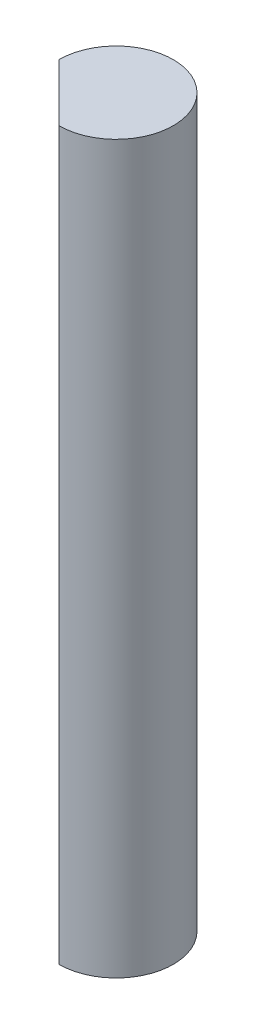
from build123d import *

# Parameters (mm, degrees)
BOSS_EXTRUDE1_DEPTH = 50.8


with BuildPart() as part:
    # Sketch1 → Boss-Extrude1 (new body)
    with BuildSketch(Plane(origin=(0, 0, 0), x_dir=(1, 0, 0), z_dir=(0, 1, 0))):
        with BuildLine():
            Line((-4, 0), (0, -4))
            ThreePointArc((0, -4), (2.828427125, 2.828427125), (-4, 0))
        make_face()
    extrude(amount=BOSS_EXTRUDE1_DEPTH)


solid = part.part
